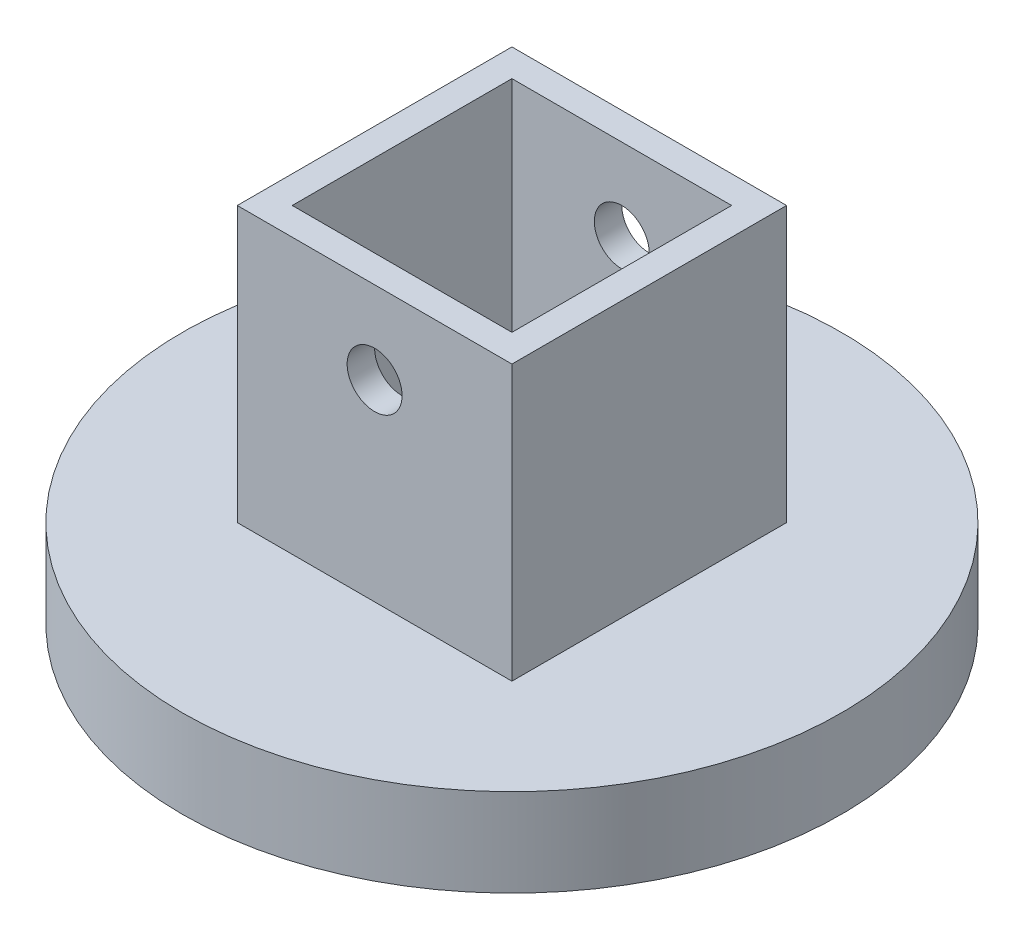
from build123d import *

# Parameters (mm, degrees)
SKETCH1_R           = 38.1
BOSS_EXTRUDE1_DEPTH = 10.16
SKETCH2_W           = 31.75
SKETCH2_H           = 31.75
BOSS_EXTRUDE3_DEPTH = 31.75
SKETCH3_W           = 25.4
SKETCH3_H           = 25.4
CUT_EXTRUDE1_DEPTH  = 42.91
SKETCH4_R           = 3.175
CUT_EXTRUDE2_DEPTH  = 54.975


with BuildPart() as part:
    # Sketch1 → Boss-Extrude1 (new body)
    with BuildSketch(Plane(origin=(0, 0, 0), x_dir=(1, 0, 0), z_dir=(0, 1, 0))):
        Circle(SKETCH1_R)
    extrude(amount=BOSS_EXTRUDE1_DEPTH)

    # Sketch2 → Boss-Extrude3 (add)
    with BuildSketch(Plane(origin=(0, 10.16, 0), x_dir=(1, 0, 0), z_dir=(0, 1, 0))):
        Rectangle(SKETCH2_W, SKETCH2_H)
    extrude(amount=BOSS_EXTRUDE3_DEPTH)

    # Sketch3 → Cut-Extrude1 (cut, through all)
    with BuildSketch(Plane(origin=(0, 41.91, 0), x_dir=(1, 0, 0), z_dir=(0, 1, 0))):
        Rectangle(SKETCH3_W, SKETCH3_H)
    extrude(amount=-CUT_EXTRUDE1_DEPTH, mode=Mode.SUBTRACT)

    # Sketch4 → Cut-Extrude2 (cut, through all)
    with BuildSketch(Plane.XY.offset(15.875)):
        with Locations((0, 32.385)):
            Circle(SKETCH4_R)
    extrude(amount=-CUT_EXTRUDE2_DEPTH, mode=Mode.SUBTRACT)


solid = part.part
